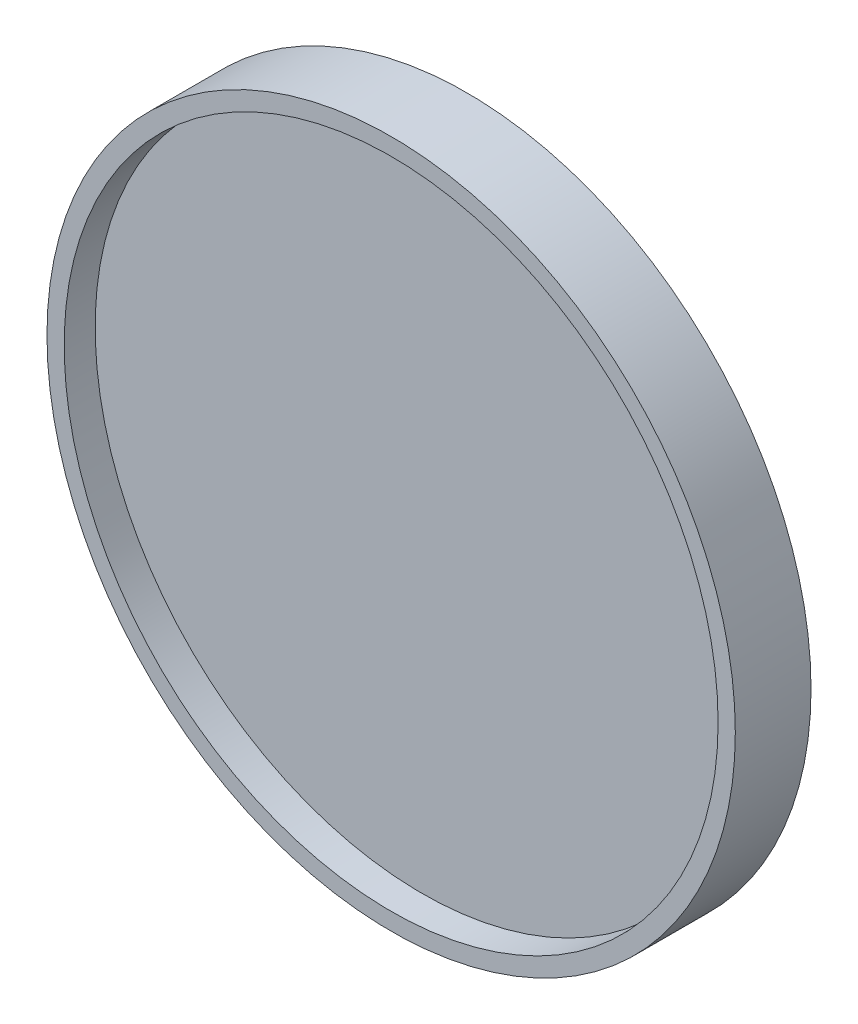
from build123d import *

# Parameters (mm, degrees)
SKETCH1_R           = 25
SKETCH1_R_2         = 23.75
BOSS_EXTRUDE1_DEPTH = 2.75
SKETCH2_R           = 23.75
BOSS_EXTRUDE2_DEPTH = 0.5


with BuildPart() as part:
    # Sketch1 → Boss-Extrude1 (new body, symmetric)
    with BuildSketch(Plane.XY):
        Circle(SKETCH1_R)
        Circle(SKETCH1_R_2, mode=Mode.SUBTRACT)
    extrude(amount=BOSS_EXTRUDE1_DEPTH, both=True)

    # Sketch2 → Boss-Extrude2 (add, symmetric)
    with BuildSketch(Plane.XY):
        Circle(SKETCH2_R)
    extrude(amount=BOSS_EXTRUDE2_DEPTH, both=True)


solid = part.part
